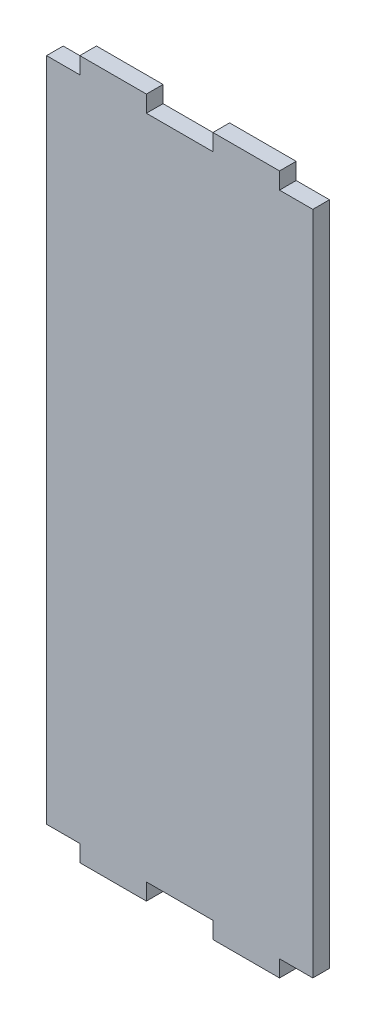
from build123d import *

# Parameters (mm, degrees)
SKETCH1_W           = 80
SKETCH1_H           = 200
BOSS_EXTRUDE1_DEPTH = 5
SKETCH2_W           = 20
SKETCH2_H           = 5
BOSS_EXTRUDE2_DEPTH = 5


with BuildPart() as part:
    # Sketch1 → Boss-Extrude1 (new body)
    with BuildSketch(Plane.XY):
        with Locations((-40, 100)):
            Rectangle(SKETCH1_W, SKETCH1_H)
    extrude(amount=BOSS_EXTRUDE1_DEPTH)

    # Sketch2 → Boss-Extrude2 (add)
    with BuildSketch(Plane.XY.offset(5)):
        with Locations((-20, 202.5)):
            Rectangle(SKETCH2_W, SKETCH2_H)
        with Locations((-60, 202.5)):
            Rectangle(SKETCH2_W, SKETCH2_H)
        with Locations((-60, -2.5)):
            Rectangle(SKETCH2_W, SKETCH2_H)
        with Locations((-20, -2.5)):
            Rectangle(SKETCH2_W, SKETCH2_H)
    extrude(amount=-BOSS_EXTRUDE2_DEPTH)


solid = part.part
